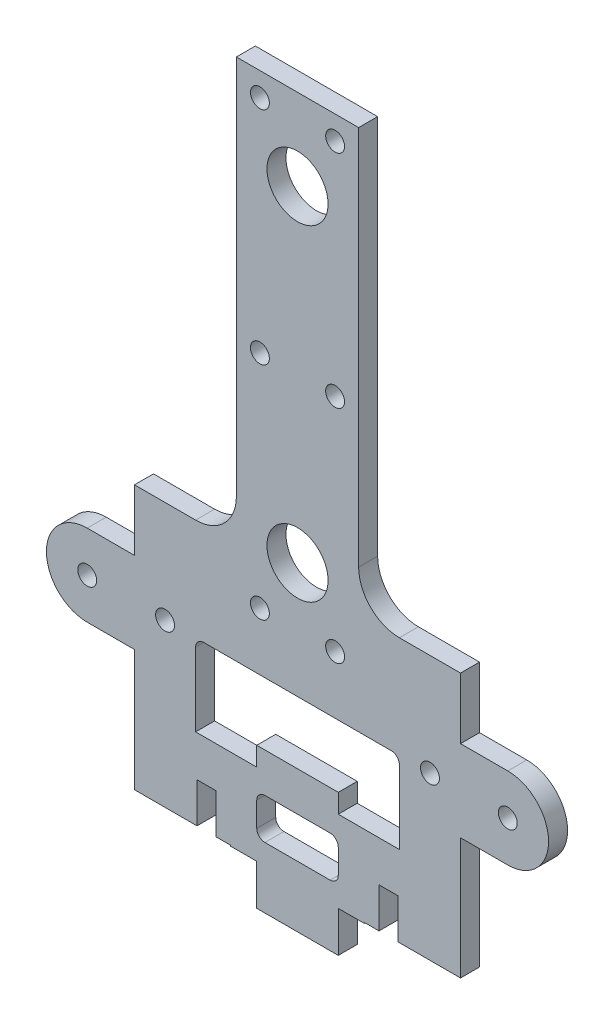
from build123d import *

# Parameters (mm, degrees)
SKETCH1_R                        = 1.4732
BOSS_EXTRUDE1_DEPTH              = 2.9591
SKETCH4_W                        = 2.9591
SKETCH4_H                        = 6.35
CUT_EXTRUDE2_DEPTH               = 2.9591
BOSS_EXTRUDE5_DEPTH              = 2.9591
FILLET2_R                        = 1.27
FILLET3_R                        = 6.35
F_3_8_0_375_DIAMETER_HOLE1_D     = 9.525
F_3_8_0_375_DIAMETER_HOLE1_DEPTH = 6.35
F_3_8_0_375_DIAMETER_HOLE1_TIP   = 2.861598698
F_4_CLEARANCE_HOLE1_D            = 2.9464
F_4_CLEARANCE_HOLE1_DEPTH        = 6.35
F_4_CLEARANCE_HOLE1_TIP          = 0.885187864
F_4_CLEARANCE_HOLE2_D            = 2.9464
F_4_CLEARANCE_HOLE2_DEPTH        = 3.302
F_4_CLEARANCE_HOLE2_TIP          = 0.885187864
SKETCH23_W                       = 14.996716291
SKETCH23_H                       = 0.127
CUT_EXTRUDE4_DEPTH               = 2.9591


with BuildPart() as part:
    # Sketch1 → Boss-Extrude1 (new body)
    with BuildSketch(Plane.XY):
        with BuildLine():
            Line((6.35, -25.4), (6.35, -31.75))
            Line((6.35, -31.75), (-6.35, -31.75))
            Line((-6.35, -31.75), (-6.35, -25.4))
            Line((-6.35, -25.4), (-25.4, -25.4))
            Line((-25.4, -25.4), (-25.4, -6.35))
            Line((-25.4, -6.35), (-32.766, -6.35))
            ThreePointArc((-32.766, -6.35), (-39.116, 0), (-32.766, 6.35))
            Line((-32.766, 6.35), (-15.875, 6.35))
            Line((-15.875, 6.35), (-15.875, -12.7))
            Line((-15.875, -12.7), (-6.35, -12.7))
            Line((-6.35, -12.7), (-6.35, -9.7409))
            Line((-6.35, -9.7409), (6.35, -9.7409))
            Line((6.35, -9.7409), (6.35, -12.7))
            Line((6.35, -12.7), (15.875, -12.7))
            Line((15.875, -12.7), (15.875, 6.35))
            Line((15.875, 6.35), (32.766, 6.35))
            ThreePointArc((32.766, 6.35), (39.116, 0), (32.766, -6.35))
            Line((32.766, -6.35), (25.4, -6.35))
            Line((25.4, -6.35), (25.4, -25.4))
            Line((25.4, -25.4), (6.35, -25.4))
        make_face()
        with Locations((32.766, 0)):
            Circle(SKETCH1_R, mode=Mode.SUBTRACT)
        with Locations((-32.766, 0)):
            Circle(SKETCH1_R, mode=Mode.SUBTRACT)
        with BuildLine():
            Line((-5.08, -15.875), (5.08, -15.875))
            ThreePointArc((5.08, -15.875), (5.978025612, -16.246974388), (6.35, -17.145))
            Line((6.35, -17.145), (6.35, -20.955))
            ThreePointArc((6.35, -20.955), (5.978025612, -21.853025612), (5.08, -22.225))
            Line((5.08, -22.225), (-5.08, -22.225))
            ThreePointArc((-5.08, -22.225), (-5.978025612, -21.853025612), (-6.35, -20.955))
            Line((-6.35, -20.955), (-6.35, -17.145))
            ThreePointArc((-6.35, -17.145), (-5.978025612, -16.246974388), (-5.08, -15.875))
        make_face(mode=Mode.SUBTRACT)
    extrude(amount=BOSS_EXTRUDE1_DEPTH)

    # Sketch4 → Cut-Extrude2 (cut)
    with BuildSketch(Plane.XY.offset(2.9591)):
        with Locations((14.17955, -22.225)):
            Rectangle(SKETCH4_W, SKETCH4_H)
    cut_extrude2 = extrude(amount=-CUT_EXTRUDE2_DEPTH, mode=Mode.SUBTRACT)

    # Mirror2: Cut-Extrude2 across plane
    add(cut_extrude2.mirror(Plane(origin=(0, 0, 0), x_dir=(0, 0, 1), z_dir=(1, 0, 0))), mode=Mode.SUBTRACT)

    # Sketch10 → Boss-Extrude5 (add)
    with BuildSketch(Plane(origin=(0, 0, 0), x_dir=(-1, 0, 0), z_dir=(0, 0, -1))):
        Polygon((25.4, 6.35), (15.875, 6.35), (15.875, 0), (-15.875, 0), (-15.875, 6.35), (-25.4, 6.35), (-25.4, 15.875), (-9.525, 15.875), (-9.525, 81.541278797), (9.525, 81.541278797), (9.525, 15.875), (25.4, 15.875), align=None)
    extrude(amount=-BOSS_EXTRUDE5_DEPTH)

    # Fillet2
    fillet2_edges = [part.edges().sort_by_distance(p)[0] for p in [
        (15.875, 0, 1.47955),
        (-15.875, 0, 1.47955),
    ]]
    fillet(fillet2_edges, radius=FILLET2_R)

    # Fillet3
    fillet3_edges = [part.edges().sort_by_distance(p)[0] for p in [
        (-9.525, 15.875, 1.47955),
        (9.525, 15.875, 1.47955),
    ]]
    fillet(fillet3_edges, radius=FILLET3_R)

    # 3/8 (0.375) Diameter Hole1
    with Locations(Plane.XY.offset(2.9591)):
        with Locations((0, 68.841278797), (0, 18.041278797)):
            Hole(F_3_8_0_375_DIAMETER_HOLE1_D / 2, depth=F_3_8_0_375_DIAMETER_HOLE1_DEPTH)
            with Locations((0, 0, -(F_3_8_0_375_DIAMETER_HOLE1_DEPTH + F_3_8_0_375_DIAMETER_HOLE1_TIP / 2))):  # 118° drill point
                Cone(0, F_3_8_0_375_DIAMETER_HOLE1_D / 2, F_3_8_0_375_DIAMETER_HOLE1_TIP, mode=Mode.SUBTRACT)

    # #4 Clearance Hole1
    with Locations(Plane.XY.offset(2.9591)):
        with Locations((-5.858825791, 77.875104588), (-5.858825791, 43.441278797), (-5.858825791, 9.006498797), (5.858825791, 9.006498797), (5.858825791, 43.441278797), (5.858825791, 77.875104588)):
            Hole(F_4_CLEARANCE_HOLE1_D / 2, depth=F_4_CLEARANCE_HOLE1_DEPTH)
            with Locations((0, 0, -(F_4_CLEARANCE_HOLE1_DEPTH + F_4_CLEARANCE_HOLE1_TIP / 2))):  # 118° drill point
                Cone(0, F_4_CLEARANCE_HOLE1_D / 2, F_4_CLEARANCE_HOLE1_TIP, mode=Mode.SUBTRACT)

    # #4 Clearance Hole2
    with Locations(Plane.XY.offset(2.9591)):
        with Locations((-20.6375, 0), (20.6375, 0)):
            Hole(F_4_CLEARANCE_HOLE2_D / 2, depth=F_4_CLEARANCE_HOLE2_DEPTH)
            with Locations((0, 0, -(F_4_CLEARANCE_HOLE2_DEPTH + F_4_CLEARANCE_HOLE2_TIP / 2))):  # 118° drill point
                Cone(0, F_4_CLEARANCE_HOLE2_D / 2, F_4_CLEARANCE_HOLE2_TIP, mode=Mode.SUBTRACT)

    # Sketch23 → Cut-Extrude4 (cut)
    with BuildSketch(Plane.XY.offset(2.9591)):
        with Locations((-17.901641854, -25.3365)):
            Rectangle(SKETCH23_W, SKETCH23_H)
    cut_extrude4 = extrude(amount=-CUT_EXTRUDE4_DEPTH, mode=Mode.SUBTRACT)

    # Mirror3: Cut-Extrude4 across plane
    add(cut_extrude4.mirror(Plane(origin=(0, 0, 0), x_dir=(0, 0, 1), z_dir=(1, 0, 0))), mode=Mode.SUBTRACT)


solid = part.part
